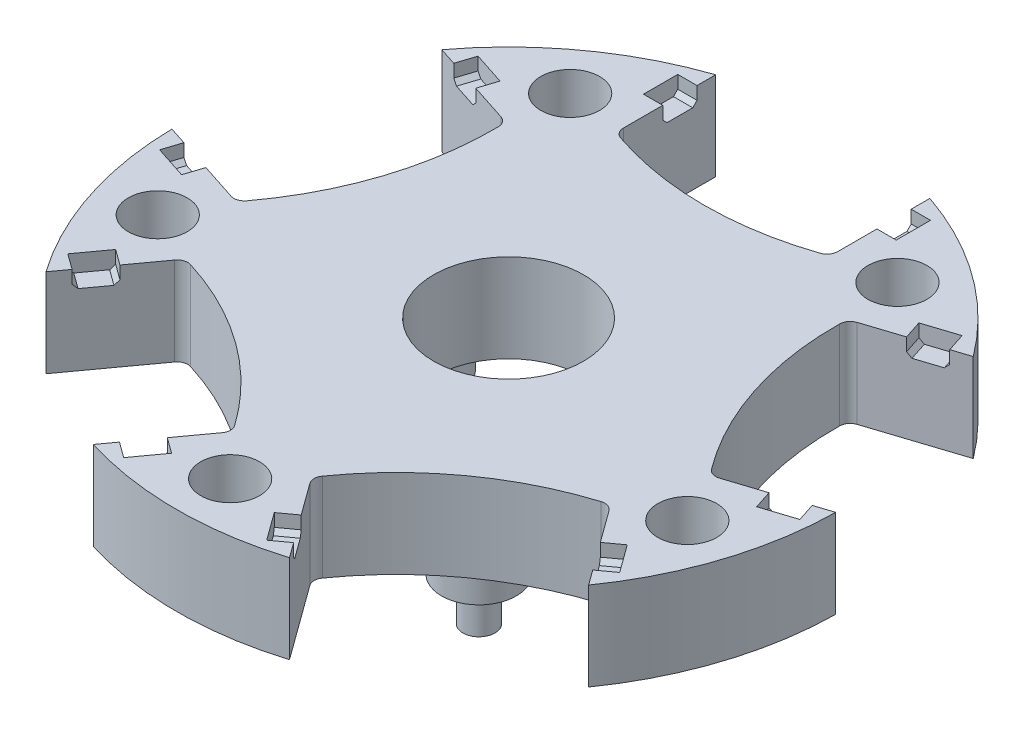
from build123d import *

# Parameters (mm, degrees)
SKETCH1_R                = 31
SKETCH1_R_2              = 7
BOSS_EXTRUDE1_DEPTH      = 8.25
CUT_EXTRUDE1_DEPTH       = 9.25
FILLET1_R                = 1
CIRPATTERN2_COUNT        = 5
FILLET1_OF_CIRPATTERN2_R = 1
CUT_EXTRUDE2_DEPTH       = 1.8
CIRPATTERN3_COUNT        = 5
CIRPATTERN3_COPY_1_DEPTH = 1.8
CIRPATTERN3_COPY_2_DEPTH = 1.8
CIRPATTERN3_COPY_3_DEPTH = 1.8
CIRPATTERN3_COPY_4_DEPTH = 1.8
SKETCH5_R                = 2.75
CUT_EXTRUDE4_DEPTH       = 9.25
CIRPATTERN4_COUNT        = 5
SKETCH8_R                = 3.5
BOSS_EXTRUDE2_DEPTH      = 3.75
SKETCH9_R                = 2
CUT_EXTRUDE6_DEPTH       = 4
SKETCH10_R               = 1.5
BOSS_EXTRUDE3_DEPTH      = 4
CIRPATTERN6_COUNT        = 5


with BuildPart() as part:
    # Sketch1 → Boss-Extrude1 (new body)
    with BuildSketch(Plane(origin=(0, 0, 0), x_dir=(1, 0, 0), z_dir=(0, 1, 0))):
        Circle(SKETCH1_R)
        Circle(SKETCH1_R_2, mode=Mode.SUBTRACT)
    extrude(amount=BOSS_EXTRUDE1_DEPTH)

    # Sketch2 → Cut-Extrude1 (cut, through all)
    with BuildSketch(Plane.XZ):
        with BuildLine():
            Line((-10, -29.342801502), (-10, -20.028684822))
            ThreePointArc((-10, -20.028684822), (0, -18.25), (10, -20.028684822))
            Line((10, -20.028684822), (10, -29.342801502))
            ThreePointArc((10, -29.342801502), (0, -31), (-10, -29.342801502))
        make_face()
    cut_extrude1 = extrude(amount=-CUT_EXTRUDE1_DEPTH, mode=Mode.SUBTRACT)

    # Fillet1
    fillet1_edges = [part.edges().sort_by_distance(p)[0] for p in [
        (-10, 4.125, -20.028684822),
        (10, 4.125, -20.028684822),
    ]]
    fillet(fillet1_edges, radius=FILLET1_R)

    # CirPattern2: Cut-Extrude1 ×5 about axis
    cirpattern2_axis = Axis((0, 0, 0), (0, 1, 0))
    for i in range(1, CIRPATTERN2_COUNT):
        add(cut_extrude1.rotate(cirpattern2_axis, i * 360 / CIRPATTERN2_COUNT), mode=Mode.SUBTRACT)

    # Fillet1 of CirPattern2
    fillet1_of_cirpattern2_edges = [part.edges().sort_by_distance(p)[0] for p in [
        (-22.138581157, 4.125, 3.321361178),
        (-15.958241269, 4.125, -15.699769148),
        (-3.682395618, 4.125, 22.081398919),
        (-19.862735505, 4.125, 10.325693873),
        (19.862735505, 4.125, 10.325693873),
        (3.682395618, 4.125, 22.081398919),
        (15.958241269, 4.125, -15.699769148),
        (22.138581157, 4.125, 3.321361178),
    ]]
    fillet(fillet1_of_cirpattern2_edges, radius=FILLET1_OF_CIRPATTERN2_R)

    # Sketch3 → Cut-Extrude2 (cut)
    with BuildSketch(Plane.ZY.offset(-10)):
        Polygon((-27.6, 8.25), (-24.4, 8.25), (-24.4, 7.05), (-24.8, 6.65), (-27.2, 6.65), (-27.6, 7.05), align=None)
    cut_extrude2 = extrude(amount=-CUT_EXTRUDE2_DEPTH, mode=Mode.SUBTRACT)

    # Mirror1: Cut-Extrude2 across plane
    add(cut_extrude2.mirror(Plane(origin=(0, 0, 0), x_dir=(0, 0, 1), z_dir=(1, 0, 0))), mode=Mode.SUBTRACT)

    # CirPattern3: Cut-Extrude2 ×5 about axis
    cirpattern3_axis = Axis((0, 0, 0), (0, 1, 0))
    for i in range(1, CIRPATTERN3_COUNT):
        add(cut_extrude2.rotate(cirpattern3_axis, i * 360 / CIRPATTERN3_COUNT), mode=Mode.SUBTRACT)

    # CirPattern3 copy 1 sketch → CirPattern3 copy 1 (cut)
    with BuildSketch(Plane(origin=(-3.090169944, 0, 9.510565163), x_dir=(0.951056516, 0, 0.309016994), z_dir=(0.309016994, 0, -0.951056516))):
        Polygon((-27.6, -8.25), (-24.4, -8.25), (-24.4, -7.05), (-24.8, -6.65), (-27.2, -6.65), (-27.6, -7.05), align=None)
    extrude(amount=-CIRPATTERN3_COPY_1_DEPTH, mode=Mode.SUBTRACT)

    # CirPattern3 copy 2 sketch → CirPattern3 copy 2 (cut)
    with BuildSketch(Plane(origin=(8.090169944, 0, 5.877852523), x_dir=(0.587785252, 0, -0.809016994), z_dir=(-0.809016994, 0, -0.587785252))):
        Polygon((-27.6, -8.25), (-24.4, -8.25), (-24.4, -7.05), (-24.8, -6.65), (-27.2, -6.65), (-27.6, -7.05), align=None)
    extrude(amount=-CIRPATTERN3_COPY_2_DEPTH, mode=Mode.SUBTRACT)

    # CirPattern3 copy 3 sketch → CirPattern3 copy 3 (cut)
    with BuildSketch(Plane(origin=(8.090169944, 0, -5.877852523), x_dir=(-0.587785252, 0, -0.809016994), z_dir=(-0.809016994, 0, 0.587785252))):
        Polygon((-27.6, -8.25), (-24.4, -8.25), (-24.4, -7.05), (-24.8, -6.65), (-27.2, -6.65), (-27.6, -7.05), align=None)
    extrude(amount=-CIRPATTERN3_COPY_3_DEPTH, mode=Mode.SUBTRACT)

    # CirPattern3 copy 4 sketch → CirPattern3 copy 4 (cut)
    with BuildSketch(Plane(origin=(-3.090169944, 0, -9.510565163), x_dir=(-0.951056516, 0, 0.309016994), z_dir=(0.309016994, 0, 0.951056516))):
        Polygon((-27.6, -8.25), (-24.4, -8.25), (-24.4, -7.05), (-24.8, -6.65), (-27.2, -6.65), (-27.6, -7.05), align=None)
    extrude(amount=-CIRPATTERN3_COPY_4_DEPTH, mode=Mode.SUBTRACT)

    # Sketch5 → Cut-Extrude4 (cut, through all)
    with BuildSketch(Plane.XZ):
        with Locations((0, 26)):
            Circle(SKETCH5_R)
    cut_extrude4 = extrude(amount=-CUT_EXTRUDE4_DEPTH, mode=Mode.SUBTRACT)

    # CirPattern4: Cut-Extrude4 ×5 about axis
    cirpattern4_axis = Axis((0, 0, 0), (0, 1, 0))
    for i in range(1, CIRPATTERN4_COUNT):
        add(cut_extrude4.rotate(cirpattern4_axis, i * 360 / CIRPATTERN4_COUNT), mode=Mode.SUBTRACT)

    # Sketch8 → Boss-Extrude2 (add)
    with BuildSketch(Plane.XZ):
        with Locations((0, -12.5)):
            Circle(SKETCH8_R)
    boss_extrude2 = extrude(amount=BOSS_EXTRUDE2_DEPTH)

    # Sketch9 → Cut-Extrude6 (cut)
    with BuildSketch(Plane.XZ):
        with Locations((0, 12.5)):
            Circle(SKETCH9_R)
    cut_extrude6 = extrude(amount=-CUT_EXTRUDE6_DEPTH, mode=Mode.SUBTRACT)

    # Sketch10 → Boss-Extrude3 (add)
    with BuildSketch(Plane.XZ.offset(3.75)):
        with Locations((0, -12.5)):
            Circle(SKETCH10_R)
    boss_extrude3 = extrude(amount=BOSS_EXTRUDE3_DEPTH)

    # CirPattern6: Boss-Extrude2, Cut-Extrude6, Boss-Extrude3 ×5 about axis
    cirpattern6_axis = Axis((0, 0, 0), (0, 1, 0))
    for i in range(1, CIRPATTERN6_COUNT):
        add(boss_extrude2.rotate(cirpattern6_axis, i * 360 / CIRPATTERN6_COUNT))
        add(cut_extrude6.rotate(cirpattern6_axis, i * 360 / CIRPATTERN6_COUNT), mode=Mode.SUBTRACT)
        add(boss_extrude3.rotate(cirpattern6_axis, i * 360 / CIRPATTERN6_COUNT))


solid = part.part
